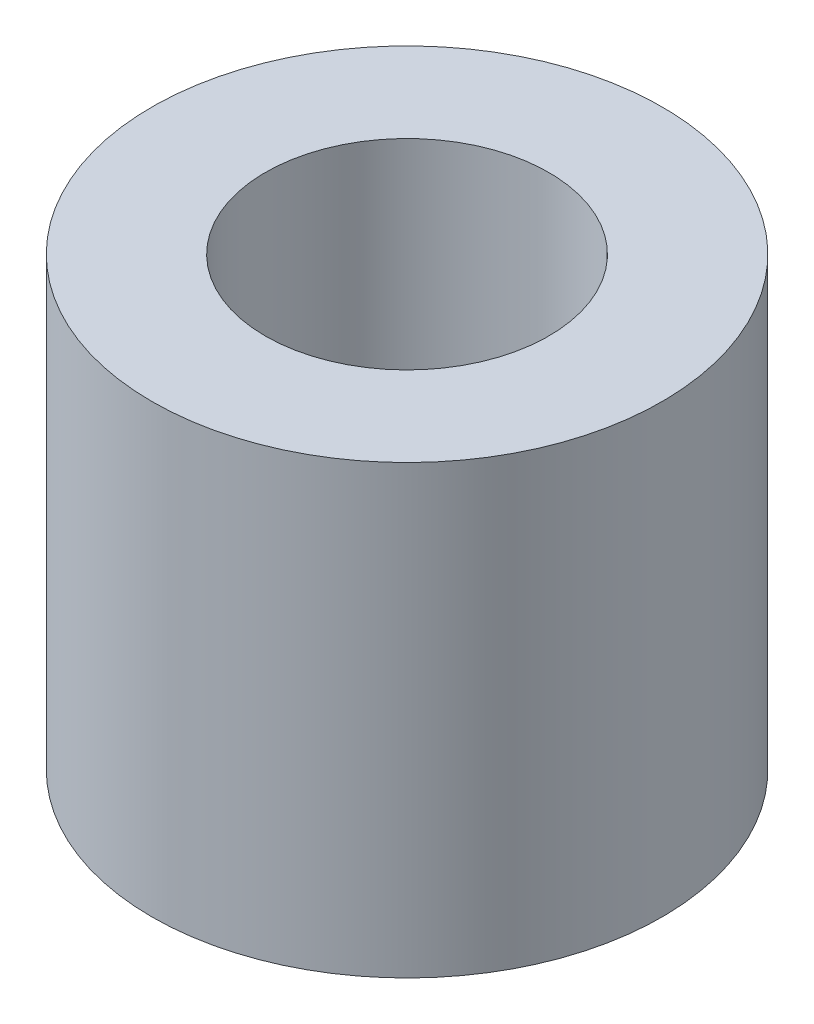
from build123d import *

# Parameters (mm, degrees)
SKETCH1_R           = 5.715
SKETCH1_R_2         = 3.175
BOSS_EXTRUDE1_DEPTH = 10


with BuildPart() as part:
    # Sketch1 → Boss-Extrude1 (new body)
    with BuildSketch(Plane(origin=(0, 0, 0), x_dir=(1, 0, 0), z_dir=(0, 1, 0))):
        Circle(SKETCH1_R)
        Circle(SKETCH1_R_2, mode=Mode.SUBTRACT)
    extrude(amount=BOSS_EXTRUDE1_DEPTH)


solid = part.part
